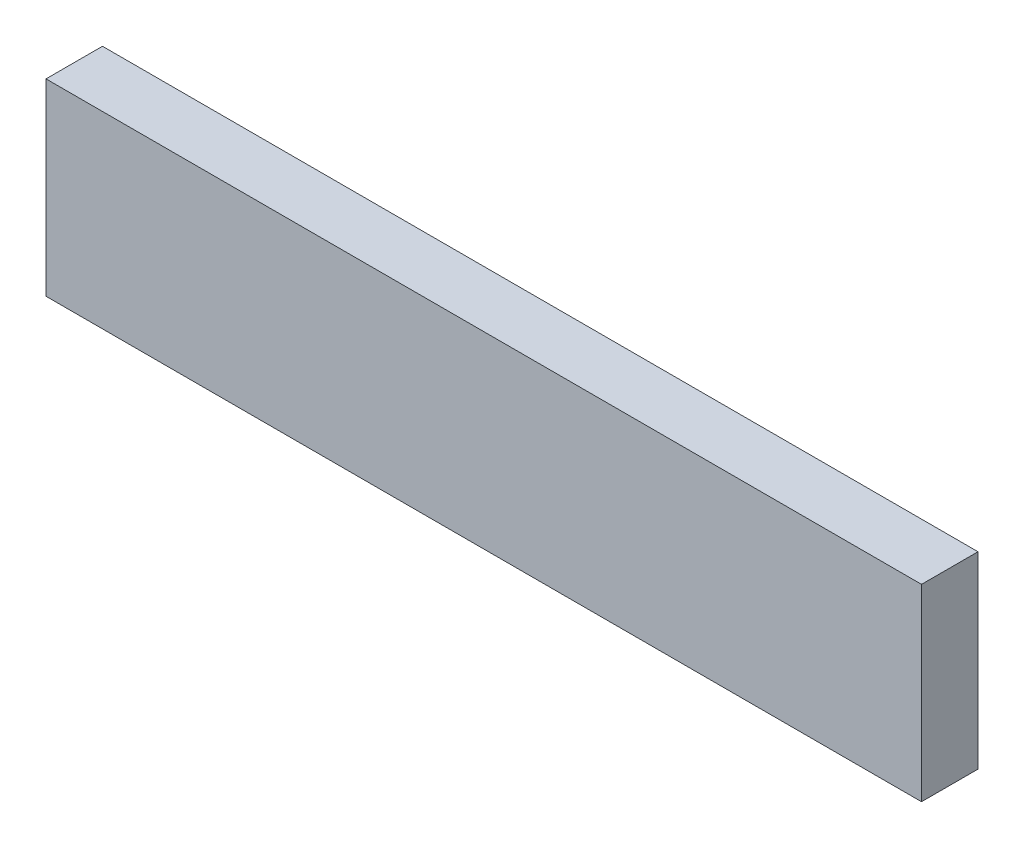
from build123d import *

# Parameters (mm, degrees)
SKETCH1_W           = 19.05
SKETCH1_H           = 63.5
BOSS_EXTRUDE1_DEPTH = 295.275


with BuildPart() as part:
    # Sketch1 → Boss-Extrude1 (new body)
    with BuildSketch(Plane(origin=(0, 0, 0), x_dir=(0, 0, -1), z_dir=(1, 0, 0))):
        Rectangle(SKETCH1_W, SKETCH1_H)
    extrude(amount=BOSS_EXTRUDE1_DEPTH)


solid = part.part
